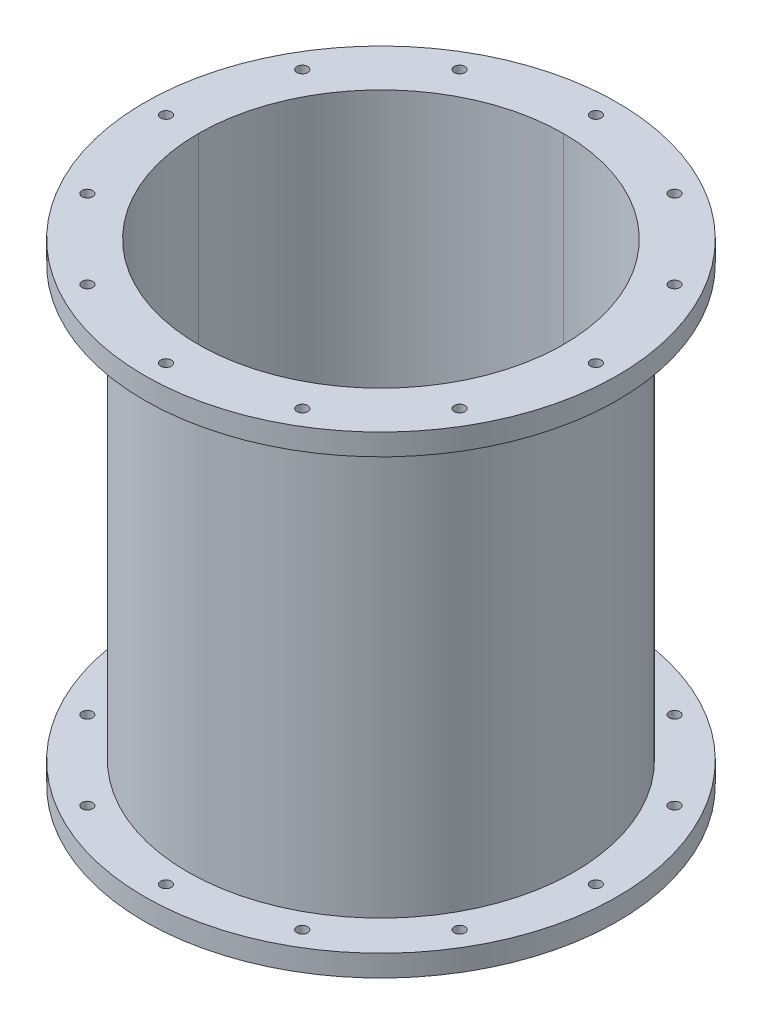
from build123d import *

# Parameters (mm, degrees)
SKETCH1_R           = 139.7
SKETCH1_R_2         = 107.95
SKETCH1_R_3         = 3.175
BOSS_EXTRUDE1_DEPTH = 139.7
SKETCH6_R           = 139.7
SKETCH6_R_2         = 3.175
SKETCH6_R_3         = 114.286339031
CUT_EXTRUDE4_DEPTH  = 127


with BuildPart() as part:
    # Sketch1 → Boss-Extrude1 (new body, symmetric)
    with BuildSketch(Plane(origin=(0, 0, 0), x_dir=(1, 0, 0), z_dir=(0, 1, 0))):
        Circle(SKETCH1_R)
        Circle(SKETCH1_R_2, mode=Mode.SUBTRACT)
        with Locations((0, 127)):
            Circle(SKETCH1_R_3, mode=Mode.SUBTRACT)
        with Locations((127, 0)):
            Circle(SKETCH1_R_3, mode=Mode.SUBTRACT)
        with Locations((63.5, 109.985226281)):
            Circle(SKETCH1_R_3, mode=Mode.SUBTRACT)
        with Locations((109.985226281, 63.5)):
            Circle(SKETCH1_R_3, mode=Mode.SUBTRACT)
        with Locations((109.985226281, -63.5)):
            Circle(SKETCH1_R_3, mode=Mode.SUBTRACT)
        with Locations((63.5, -109.985226281)):
            Circle(SKETCH1_R_3, mode=Mode.SUBTRACT)
        with Locations((0, -127)):
            Circle(SKETCH1_R_3, mode=Mode.SUBTRACT)
        with Locations((-63.5, -109.985226281)):
            Circle(SKETCH1_R_3, mode=Mode.SUBTRACT)
        with Locations((-109.985226281, -63.5)):
            Circle(SKETCH1_R_3, mode=Mode.SUBTRACT)
        with Locations((-127, 0)):
            Circle(SKETCH1_R_3, mode=Mode.SUBTRACT)
        with Locations((-109.985226281, 63.5)):
            Circle(SKETCH1_R_3, mode=Mode.SUBTRACT)
        with Locations((-63.5, 109.985226281)):
            Circle(SKETCH1_R_3, mode=Mode.SUBTRACT)
    extrude(amount=BOSS_EXTRUDE1_DEPTH, both=True)

    # Sketch6 → Cut-Extrude4 (cut, symmetric)
    with BuildSketch(Plane(origin=(0, 0, 0), x_dir=(1, 0, 0), z_dir=(0, 1, 0))):
        Circle(SKETCH6_R)
        with Locations((-63.5, 109.985226281)):
            Circle(SKETCH6_R_2, mode=Mode.SUBTRACT)
        with Locations((0, 127)):
            Circle(SKETCH6_R_2, mode=Mode.SUBTRACT)
        with Locations((63.5, 109.985226281)):
            Circle(SKETCH6_R_2, mode=Mode.SUBTRACT)
        with Locations((109.985226281, 63.5)):
            Circle(SKETCH6_R_2, mode=Mode.SUBTRACT)
        with Locations((127, 0)):
            Circle(SKETCH6_R_2, mode=Mode.SUBTRACT)
        with Locations((109.985226281, -63.5)):
            Circle(SKETCH6_R_2, mode=Mode.SUBTRACT)
        with Locations((63.5, -109.985226281)):
            Circle(SKETCH6_R_2, mode=Mode.SUBTRACT)
        with Locations((0, -127)):
            Circle(SKETCH6_R_2, mode=Mode.SUBTRACT)
        with Locations((-63.5, -109.985226281)):
            Circle(SKETCH6_R_2, mode=Mode.SUBTRACT)
        with Locations((-109.985226281, -63.5)):
            Circle(SKETCH6_R_2, mode=Mode.SUBTRACT)
        with Locations((-127, 0)):
            Circle(SKETCH6_R_2, mode=Mode.SUBTRACT)
        with Locations((-109.985226281, 63.5)):
            Circle(SKETCH6_R_2, mode=Mode.SUBTRACT)
        Circle(SKETCH6_R_3, mode=Mode.SUBTRACT)
    extrude(amount=CUT_EXTRUDE4_DEPTH, both=True, mode=Mode.SUBTRACT)


solid = part.part
